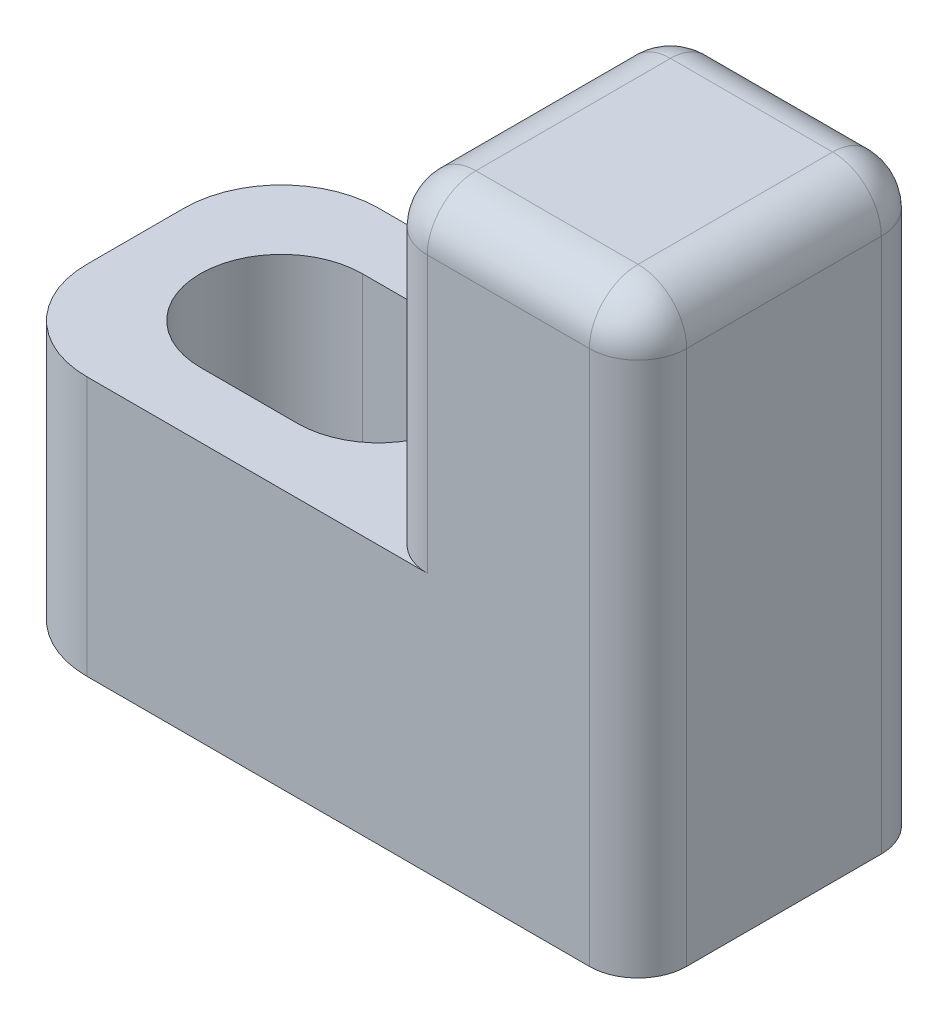
from build123d import *

# Parameters (mm, degrees)
SKETCH1_W           = 20
SKETCH1_H           = 9
BOSS_EXTRUDE1_DEPTH = 8
SKETCH2_W           = 8
SKETCH2_H           = 9
BOSS_EXTRUDE2_DEPTH = 10
FILLET1_R           = 3
FILLET3_R           = 1.5


with BuildPart() as part:
    # Sketch1 → Boss-Extrude1 (new body)
    with BuildSketch(Plane(origin=(0, 0, 0), x_dir=(1, 0, 0), z_dir=(0, 1, 0))):
        Rectangle(SKETCH1_W, SKETCH1_H)
        with BuildLine():
            Line((-5.5, 2.5), (-2.5, 2.5))
            ThreePointArc((-2.5, 2.5), (0, 0), (-2.5, -2.5))
            Line((-2.5, -2.5), (-5.5, -2.5))
            ThreePointArc((-5.5, -2.5), (-8, 0), (-5.5, 2.5))
        make_face(mode=Mode.SUBTRACT)
    extrude(amount=BOSS_EXTRUDE1_DEPTH)

    # Sketch2 → Boss-Extrude2 (add)
    with BuildSketch(Plane(origin=(0, 8, 0), x_dir=(1, 0, 0), z_dir=(0, 1, 0))):
        with Locations((6, 0)):
            Rectangle(SKETCH2_W, SKETCH2_H)
    extrude(amount=BOSS_EXTRUDE2_DEPTH)

    # Fillet1
    fillet1_edges = [part.edges().sort_by_distance(p)[0] for p in [
        (-10, 4, 4.5),
        (-10, 4, -4.5),
    ]]
    fillet(fillet1_edges, radius=FILLET1_R)

    # Fillet3
    fillet3_edges = [part.edges().sort_by_distance(p)[0] for p in [
        (2, 13, -4.5),
        (2, 13, 4.5),
        (10, 18, 0),
        (6, 18, -4.5),
        (2, 18, 0),
        (6, 18, 4.5),
        (10, 9, 4.5),
        (10, 9, -4.5),
    ]]
    fillet(fillet3_edges, radius=FILLET3_R)


solid = part.part
